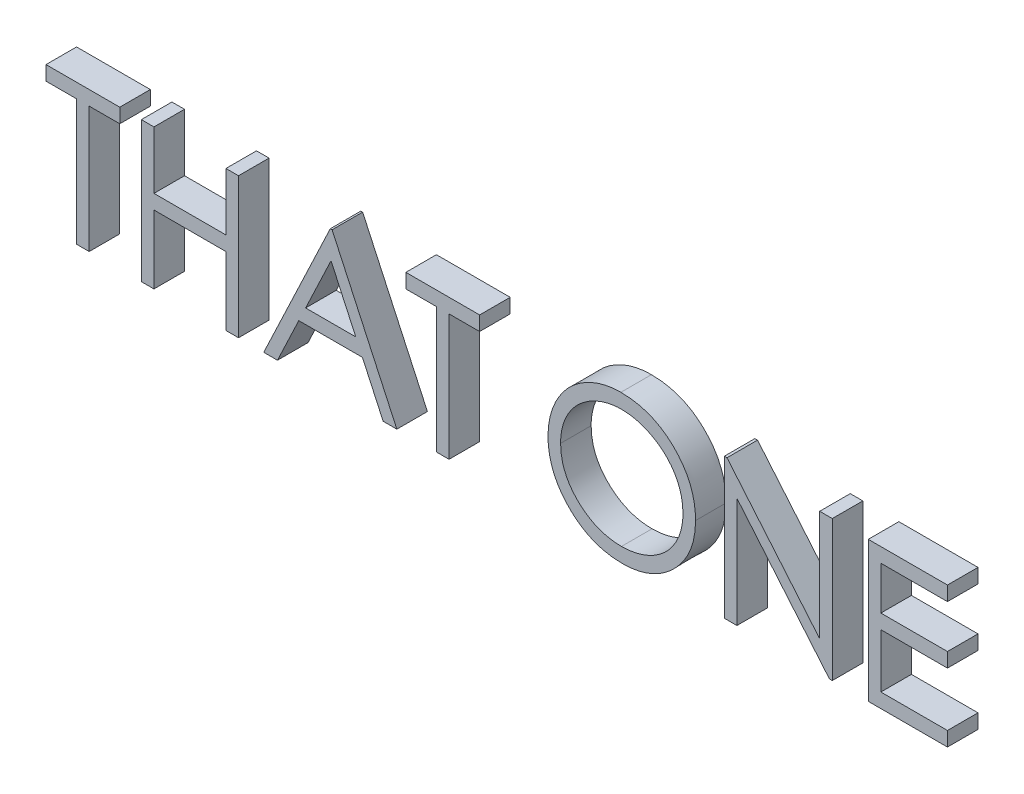
from build123d import *

# Parameters (mm, degrees)
BOSS_EXTRUDE1_DEPTH   = 0.762
BOSS_EXTRUDE1_2_DEPTH = 0.762
BOSS_EXTRUDE1_3_DEPTH = 0.762
BOSS_EXTRUDE1_4_DEPTH = 0.762
BOSS_EXTRUDE1_5_DEPTH = 0.762
BOSS_EXTRUDE1_6_DEPTH = 0.762
BOSS_EXTRUDE1_7_DEPTH = 0.762


with BuildPart() as part:
    # Sketch1 → Boss-Extrude1 (new body)
    with BuildSketch(Plane.XY):
        Polygon((0.044871795, 3.141025641), (0.044871795, 3.5), (1.884615385, 3.5), (1.884615385, 3.141025641), (1.121794872, 3.141025641), (1.121794872, 0), (0.807692308, 0), (0.807692308, 3.141025641), align=None)
    extrude(amount=BOSS_EXTRUDE1_DEPTH)


with BuildPart() as body_2:
    # Sketch1 → Boss-Extrude1 2 (new body)
    with BuildSketch(Plane.XY):
        Polygon((2.423076923, 3.5), (2.737179487, 3.5), (2.737179487, 2.064102564), (4.532051282, 2.064102564), (4.532051282, 3.5), (4.846153846, 3.5), (4.846153846, 0), (4.532051282, 0), (4.532051282, 1.705128205), (2.737179487, 1.705128205), (2.737179487, 0), (2.423076923, 0), align=None)
    extrude(amount=BOSS_EXTRUDE1_2_DEPTH)


with BuildPart() as body_3:
    # Sketch1 → Boss-Extrude1 3 (new body)
    with BuildSketch(Plane.XY):
        Polygon((7.179487179, 3.5), (8.794871795, 0), (8.453425481, 0), (7.935997596, 1.121794872), (6.349358974, 1.121794872), (5.817207532, 0), (5.474358974, 0), (7.134615385, 3.5), align=None)
        Polygon((7.153545673, 2.817808494), (6.519731571, 1.480769231), (7.770532853, 1.480769231), align=None, mode=Mode.SUBTRACT)
    extrude(amount=BOSS_EXTRUDE1_3_DEPTH)


with BuildPart() as body_4:
    # Sketch1 → Boss-Extrude1 4 (new body)
    with BuildSketch(Plane.XY):
        Polygon((9.019230769, 3.141025641), (9.019230769, 3.5), (10.858974359, 3.5), (10.858974359, 3.141025641), (10.096153846, 3.141025641), (10.096153846, 0), (9.782051282, 0), (9.782051282, 3.141025641), align=None)
    extrude(amount=BOSS_EXTRUDE1_4_DEPTH)


with BuildPart() as body_5:
    # Sketch1 → Boss-Extrude1 5 (new body)
    with BuildSketch(Plane.XY):
        with BuildLine():
            add(Edge.make_bspline(
                [(14.381410256, 3.58974359), (14.446218362, 3.58810211), (14.573506829, 3.584878109), (14.760581727, 3.560199006), (14.939176822, 3.517503616), (15.110746961, 3.460640633), (15.273239938, 3.384786248), (15.42787883, 3.2931011), (15.574295704, 3.184624641), (15.710517085, 3.060195414), (15.835174036, 2.92481196), (15.944999922, 2.78033405), (16.037042216, 2.627635248), (16.112628003, 2.467174417), (16.171926613, 2.299314449), (16.212845656, 2.123160446), (16.238983806, 1.939853756), (16.242039584, 1.814826892), (16.243589744, 1.751402244)],
                knots=[0, 0, 0, 0, 1.065120563, 2.091984664, 3.0946048, 4.079830382, 5.057816894, 6.036188127, 7.030412546, 8.04752943, 9.064399622, 10.05169764, 11.02544977, 11.989514704, 12.962713494, 13.945757189, 14.957906945, 16, 16, 16, 16], degree=3))
            add(Edge.make_bspline(
                [(16.243589744, 1.751402244), (16.242039811, 1.688444797), (16.238984714, 1.564348377), (16.212815937, 1.382204933), (16.171774937, 1.207114236), (16.113178671, 1.039368583), (16.037953192, 0.87879102), (15.945298021, 0.725804066), (15.83615681, 0.580357567), (15.711949959, 0.444044902), (15.576548917, 0.319047431), (15.431318651, 0.210128556), (15.279525331, 0.116404431), (15.119215623, 0.041620757), (14.952515586, -0.018151163), (14.777933263, -0.058903793), (14.596286709, -0.085190837), (14.472415705, -0.088209353), (14.409455128, -0.08974359)],
                knots=[0, 0, 0, 0, 1.043624062, 2.057103931, 3.04512605, 4.022047818, 4.998200453, 5.980619268, 6.982898556, 8.009068085, 9.034988726, 10.034168286, 11.015286542, 11.987931943, 12.962482838, 13.94673481, 14.956375938, 16, 16, 16, 16], degree=3))
            add(Edge.make_bspline(
                [(14.409455128, -0.08974359), (14.346030809, -0.088194203), (14.221004593, -0.085139949), (14.037467558, -0.058958544), (13.861189814, -0.01801724), (13.692675463, 0.040492196), (13.531830533, 0.116109427), (13.378340451, 0.208313806), (13.232821303, 0.317720947), (13.096479557, 0.441887521), (12.971730359, 0.577059073), (12.862970983, 0.721893329), (12.77074587, 0.873548785), (12.695382537, 1.032446309), (12.635718078, 1.197817752), (12.59501326, 1.370766229), (12.568677308, 1.550305735), (12.565642461, 1.672548634), (12.564102564, 1.734575321)],
                knots=[0, 0, 0, 0, 1.053102029, 2.075944431, 3.073151272, 4.055350789, 5.033113405, 6.020478099, 7.024410459, 8.052272461, 9.079885166, 10.07527673, 11.055994387, 12.023226415, 12.992069828, 13.970394897, 14.97016774, 16, 16, 16, 16], degree=3))
            add(Edge.make_bspline(
                [(12.564102564, 1.734575321), (12.5646372, 1.77620799), (12.565699726, 1.858948113), (12.578491418, 1.981814713), (12.59705312, 2.102705371), (12.623655032, 2.221276319), (12.658446699, 2.337237304), (12.699498727, 2.451388067), (12.749638572, 2.56257179), (12.80631922, 2.671315182), (12.869581028, 2.775923088), (12.939456777, 2.874802671), (13.013492146, 2.968783668), (13.09465554, 3.055430672), (13.180271985, 3.137264328), (13.271730363, 3.213027045), (13.368472607, 3.283401996), (13.470914987, 3.346822337), (13.576533262, 3.404181472), (13.68541004, 3.453403323), (13.796066611, 3.495649384), (13.909021259, 3.529890209), (14.023974031, 3.556922245), (14.141175816, 3.575329599), (14.260533242, 3.588153917), (14.340944561, 3.589211419), (14.381410256, 3.58974359)],
                knots=[0, 0, 0, 0, 1.037015668, 2.060948919, 3.074880161, 4.083647147, 5.086022904, 6.090072063, 7.104153813, 8.122640571, 9.144368836, 10.147691507, 11.138137339, 12.123020368, 13.103399296, 14.087645067, 15.080126199, 16.082011238, 17.087798457, 18.072939717, 19.057185487, 20.037253025, 21.01195951, 21.997135196, 22.992090687, 24, 24, 24, 24], degree=3))
        make_face()
        with BuildLine():
            add(Edge.make_bspline(
                [(14.396834936, 3.230769231), (14.363620302, 3.230364341), (14.297508569, 3.229558431), (14.199224033, 3.218942715), (14.102232099, 3.203812826), (14.006512737, 3.182231305), (13.912466448, 3.152827253), (13.819216607, 3.118986345), (13.727613553, 3.077765254), (13.637959695, 3.03119255), (13.55104462, 2.979643629), (13.469031918, 2.922671862), (13.391709274, 2.861613307), (13.319266008, 2.79632547), (13.251914836, 2.726475868), (13.188330134, 2.653123432), (13.131060552, 2.574171541), (13.078574976, 2.491761134), (13.031607135, 2.405999553), (12.989841781, 2.317789691), (12.955677772, 2.226412004), (12.927815395, 2.132857846), (12.904715585, 2.037275387), (12.890081661, 1.938939538), (12.879349301, 1.838344426), (12.878589456, 1.770362572), (12.878205128, 1.735977564)],
                knots=[0, 0, 0, 0, 1.008559885, 2.007477868, 2.99961109, 3.989939068, 4.984837346, 5.991145699, 7.001802488, 8.033829008, 9.059044045, 10.069351652, 11.065060232, 12.050310815, 13.029377138, 14.011219647, 14.996725999, 15.989392538, 16.977580475, 17.965360261, 18.951710183, 19.937753436, 20.929683414, 21.935841486, 22.955955122, 24, 24, 24, 24], degree=3))
            add(Edge.make_bspline(
                [(12.878205128, 1.735977564), (12.87947999, 1.685415343), (12.881988038, 1.585943813), (12.903945608, 1.440175669), (12.937767583, 1.300087383), (12.987624949, 1.166445474), (13.049975564, 1.038101191), (13.127002454, 0.916193086), (13.21826154, 0.800688212), (13.321925066, 0.692392943), (13.435247773, 0.593547138), (13.555580503, 0.50678373), (13.68163411, 0.43337348), (13.813737313, 0.373568408), (13.951184852, 0.32617867), (14.094862403, 0.293700039), (14.243812863, 0.272324583), (14.345343518, 0.270271827), (14.396834936, 0.269230769)],
                knots=[0, 0, 0, 0, 1.032063989, 2.030389145, 3.003944642, 3.970395727, 4.937377036, 5.913328081, 6.909231446, 7.93887556, 8.970685674, 9.976071282, 10.964166581, 11.944589148, 12.933237628, 13.927779006, 14.949070134, 16, 16, 16, 16], degree=3))
            add(Edge.make_bspline(
                [(14.396834936, 0.269230769), (14.431444438, 0.269706274), (14.500085474, 0.270649342), (14.602180996, 0.280148018), (14.702437208, 0.295379888), (14.800713488, 0.317310543), (14.896898299, 0.34475775), (14.991393102, 0.377365478), (15.083191393, 0.418046682), (15.17345123, 0.462994633), (15.259847472, 0.514234791), (15.342323004, 0.56927294), (15.418798984, 0.630241561), (15.491188056, 0.694559374), (15.558815745, 0.763523221), (15.621224729, 0.837043443), (15.678204861, 0.9155841), (15.730670508, 0.997869506), (15.77747377, 1.083865759), (15.81825287, 1.172395437), (15.852848985, 1.263240546), (15.88077749, 1.356532118), (15.902662952, 1.452092966), (15.917742872, 1.550051045), (15.92829131, 1.650210387), (15.929086388, 1.717954243), (15.929487179, 1.752103365)],
                knots=[0, 0, 0, 0, 1.047197238, 2.076906641, 3.100256066, 4.114471768, 5.12198147, 6.126382909, 7.136867548, 8.15857795, 9.17633901, 10.174870724, 11.156907918, 12.133735059, 13.104061851, 14.077631395, 15.04955518, 16.038496417, 17.029181396, 18.010275684, 18.986308667, 19.968651475, 20.955262928, 21.950658345, 22.966943676, 24, 24, 24, 24], degree=3))
            add(Edge.make_bspline(
                [(15.929487179, 1.752103365), (15.929086067, 1.78601887), (15.928290385, 1.85329652), (15.91774791, 1.952757338), (15.90264702, 2.05001055), (15.880884312, 2.144674353), (15.852834158, 2.236772878), (15.818246828, 2.326219625), (15.777461528, 2.413347821), (15.730653304, 2.497942118), (15.678037481, 2.579116855), (15.620543237, 2.656719268), (15.557177889, 2.729292009), (15.489751864, 2.798626703), (15.416580979, 2.863244593), (15.337996685, 2.923167114), (15.254953007, 2.979840388), (15.167025772, 3.03096595), (15.076281818, 3.078180182), (14.98316786, 3.118631186), (14.88873876, 3.153003305), (14.793234648, 3.18232027), (14.69585167, 3.2037283), (14.597247841, 3.21895635), (14.497559582, 3.229554736), (14.430516362, 3.230363114), (14.396834936, 3.230769231)],
                knots=[0, 0, 0, 0, 1.02996197, 2.043119294, 3.035359645, 4.018872909, 4.991431989, 5.957985074, 6.929999688, 7.912076566, 8.892894881, 9.867085534, 10.843653904, 11.817741046, 12.803660682, 13.806313499, 14.818574707, 15.856120519, 16.894564902, 17.924820532, 18.937903209, 19.946497019, 20.957711757, 21.963978472, 22.977135795, 24, 24, 24, 24], degree=3))
        make_face(mode=Mode.SUBTRACT)
    extrude(amount=BOSS_EXTRUDE1_5_DEPTH)


with BuildPart() as body_6:
    # Sketch1 → Boss-Extrude1 6 (new body)
    with BuildSketch(Plane.XY):
        Polygon((16.961538462, 0), (16.961538462, 3.5), (17.02744391, 3.5), (19.33974359, 0.745292468), (19.33974359, 3.5), (19.653846154, 3.5), (19.653846154, 0), (19.582331731, 0), (17.275641026, 2.748397436), (17.275641026, 0), align=None)
    extrude(amount=BOSS_EXTRUDE1_6_DEPTH)


with BuildPart() as body_7:
    # Sketch1 → Boss-Extrude1 7 (new body)
    with BuildSketch(Plane.XY):
        Polygon((20.551282051, 3.5), (22.525641026, 3.5), (22.525641026, 3.141025641), (20.865384615, 3.141025641), (20.865384615, 2.064102564), (22.525641026, 2.064102564), (22.525641026, 1.705128205), (20.865384615, 1.705128205), (20.865384615, 0.358974359), (22.525641026, 0.358974359), (22.525641026, 0), (20.551282051, 0), align=None)
    extrude(amount=BOSS_EXTRUDE1_7_DEPTH)


solid = Compound([part.part, body_2.part, body_3.part, body_4.part, body_5.part, body_6.part, body_7.part])
